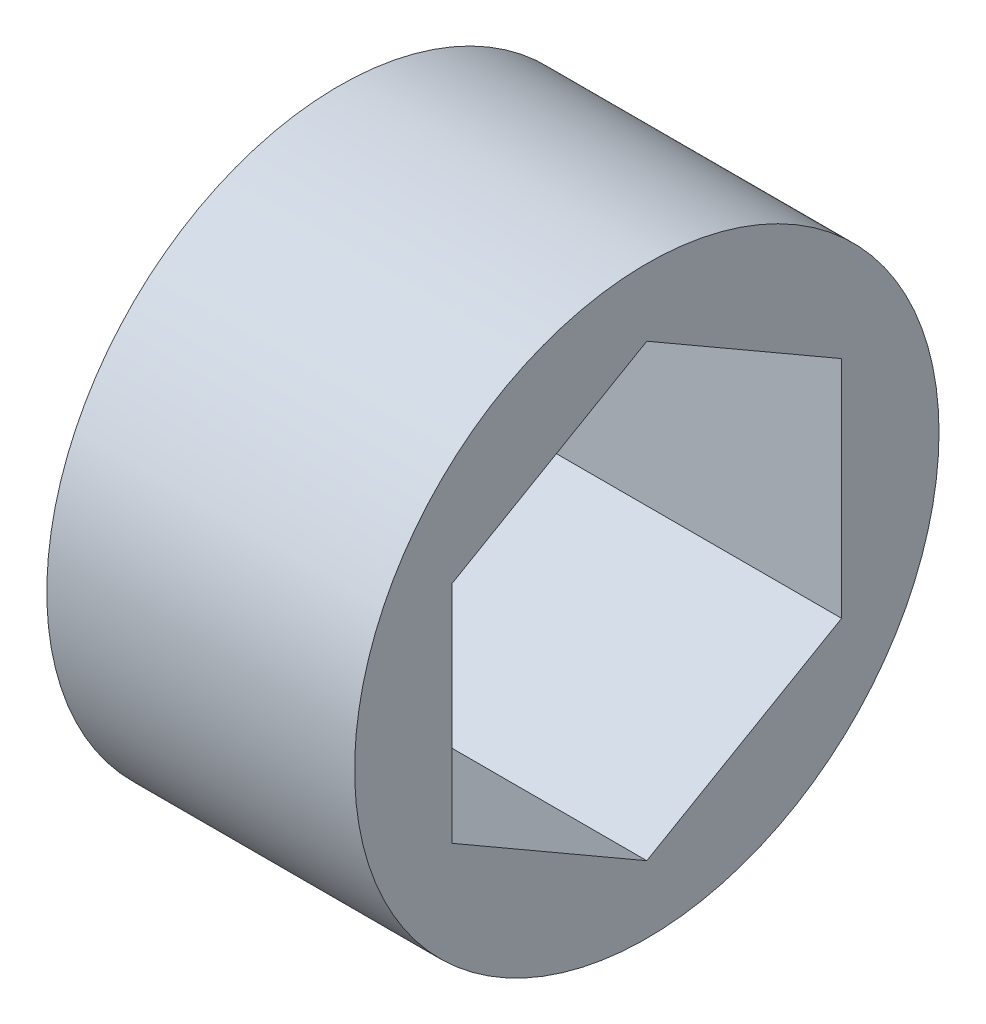
from build123d import *

# Parameters (mm, degrees)
SKETCH1_R           = 9.525
BOSS_EXTRUDE1_DEPTH = 10.033


with BuildPart() as part:
    # Sketch1 → Boss-Extrude1 (new body)
    with BuildSketch(Plane(origin=(0, 0, 0), x_dir=(0, 0, -1), z_dir=(1, 0, 0))):
        Circle(SKETCH1_R)
        Polygon((0, 7.332348419), (-6.35, 3.666174209), (-6.35, -3.666174209), (0, -7.332348419), (6.35, -3.666174209), (6.35, 3.666174209), align=None, mode=Mode.SUBTRACT)
    extrude(amount=BOSS_EXTRUDE1_DEPTH)


solid = part.part
